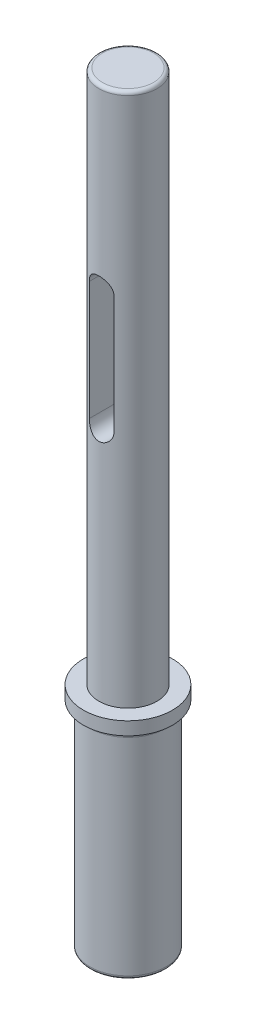
from build123d import *

# Parameters (mm, degrees)
SKETCH1_R               = 9.525
BOSS_EXTRUDE1_DEPTH     = 163.322
SKETCH2_OUTSIDE_W       = 54.156
SKETCH2_OUTSIDE_H       = 54.156
SKETCH2_OUTSIDE_R       = 8.128
CUT_EXTRUDE1_DEPTH      = 46.228
SKETCH3_OUTSIDE_W       = 54.156
SKETCH3_OUTSIDE_H       = 54.156
SKETCH3_OUTSIDE_R       = 6.223
CUT_EXTRUDE2_DEPTH      = 114.3
FILLET1_R               = 1.27
CUT_EXTRUDE3_DEPTH      = 10.525
CUT_EXTRUDE3_DEPTH_BACK = 10.525
FILLET2_R               = 0.762
FILLET3_R               = 0.762


with BuildPart() as part:
    # Sketch1 → Boss-Extrude1 (new body)
    with BuildSketch(Plane(origin=(0, 0, 0), x_dir=(1, 0, 0), z_dir=(0, 1, 0))):
        Circle(SKETCH1_R)
    extrude(amount=BOSS_EXTRUDE1_DEPTH)

    # Sketch2 outside → Cut-Extrude1 (cut)
    with BuildSketch(Plane(origin=(0, 0, 0), x_dir=(1, 0, 0), z_dir=(0, 1, 0))):
        Rectangle(SKETCH2_OUTSIDE_W, SKETCH2_OUTSIDE_H)
        Circle(SKETCH2_OUTSIDE_R, mode=Mode.SUBTRACT)
    extrude(amount=CUT_EXTRUDE1_DEPTH, mode=Mode.SUBTRACT)

    # Sketch3 outside → Cut-Extrude2 (cut)
    with BuildSketch(Plane(origin=(0, 163.322, 0), x_dir=(1, 0, 0), z_dir=(0, 1, 0))):
        Rectangle(SKETCH3_OUTSIDE_W, SKETCH3_OUTSIDE_H)
        Circle(SKETCH3_OUTSIDE_R, mode=Mode.SUBTRACT)
    extrude(amount=-CUT_EXTRUDE2_DEPTH, mode=Mode.SUBTRACT)

    # Fillet1
    fillet1_edges = [part.edges().sort_by_distance(p)[0] for p in [
        (-8.128, 46.228, 0),
    ]]
    fillet(fillet1_edges, radius=FILLET1_R)

    # Sketch4 → Cut-Extrude3 (cut, two sides)
    with BuildSketch(Plane.XY) as cut_extrude3_sk:
        with BuildLine():
            Line((2.63525, 125.222), (2.63525, 99.822))
            ThreePointArc((2.63525, 99.822), (0, 97.18675), (-2.63525, 99.822))
            Line((-2.63525, 99.822), (-2.63525, 125.222))
            ThreePointArc((-2.63525, 125.222), (0, 127.85725), (2.63525, 125.222))
        make_face()
    extrude(amount=CUT_EXTRUDE3_DEPTH, mode=Mode.SUBTRACT)
    extrude(cut_extrude3_sk.sketch, amount=-CUT_EXTRUDE3_DEPTH_BACK, mode=Mode.SUBTRACT)

    # Fillet2
    fillet2_edges = [part.edges().sort_by_distance(p)[0] for p in [
        (-6.223, 163.322, 0),
    ]]
    fillet(fillet2_edges, radius=FILLET2_R)

    # Fillet3
    fillet3_edges = [part.edges().sort_by_distance(p)[0] for p in [
        (-8.128, 0, 0),
    ]]
    fillet(fillet3_edges, radius=FILLET3_R)


solid = part.part
